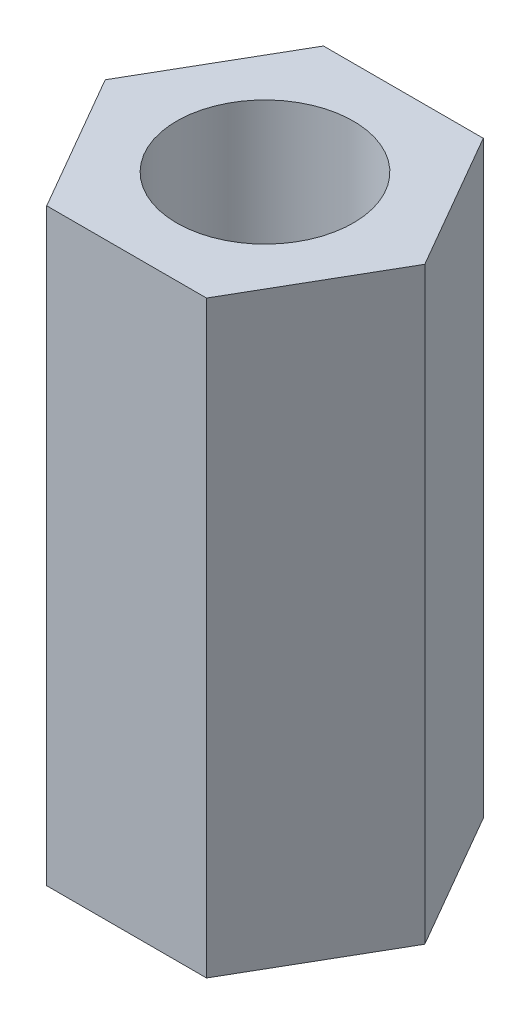
from build123d import *

# Parameters (mm, degrees)
SKETCH_1_R      = 1.5
EXTRUDE_1_DEPTH = 10


with BuildPart() as part:
    # 草图1 → 凸台-拉伸1 (new body)
    with BuildSketch(Plane(origin=(0, 0, 0), x_dir=(1, 0, 0), z_dir=(0, 1, 0))):
        Polygon((2.713546265, 0), (1.356773133, 2.35), (-1.356773133, 2.35), (-2.713546265, 0), (-1.356773133, -2.35), (1.356773133, -2.35), align=None)
        Circle(SKETCH_1_R, mode=Mode.SUBTRACT)
    extrude(amount=EXTRUDE_1_DEPTH)


solid = part.part
